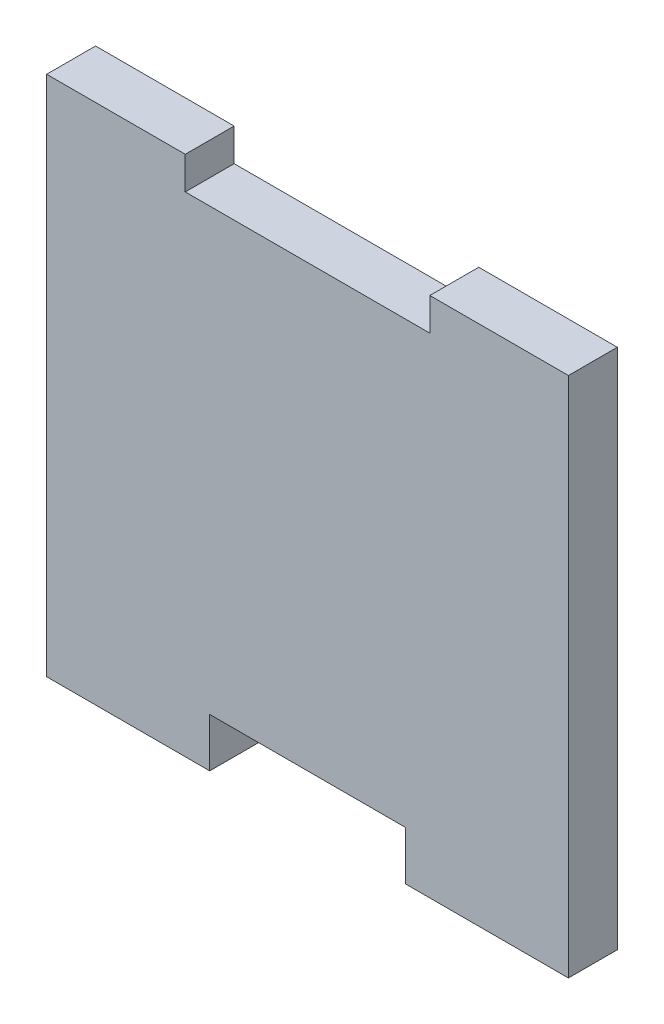
from build123d import *

# Parameters (mm, degrees)
SALIENTE_EXTRUIR1_DEPTH = 3


with BuildPart() as part:
    # Model → Saliente-Extruir1 (new body)
    with BuildSketch(Plane.XY):
        Polygon((31.875332881, 32.236157288), (23.375332881, 32.236157288), (23.375332881, 0.236157288), (33.375332881, 0.236157288), (33.375332881, 3.236157288), (45.375332881, 3.236157288), (45.375332881, 0.236157288), (55.375332881, 0.236157288), (55.375332881, 32.236157288), (46.875332881, 32.236157288), (46.875332881, 30.236157288), (31.875332881, 30.236157288), align=None)
    extrude(amount=SALIENTE_EXTRUIR1_DEPTH)


solid = part.part
